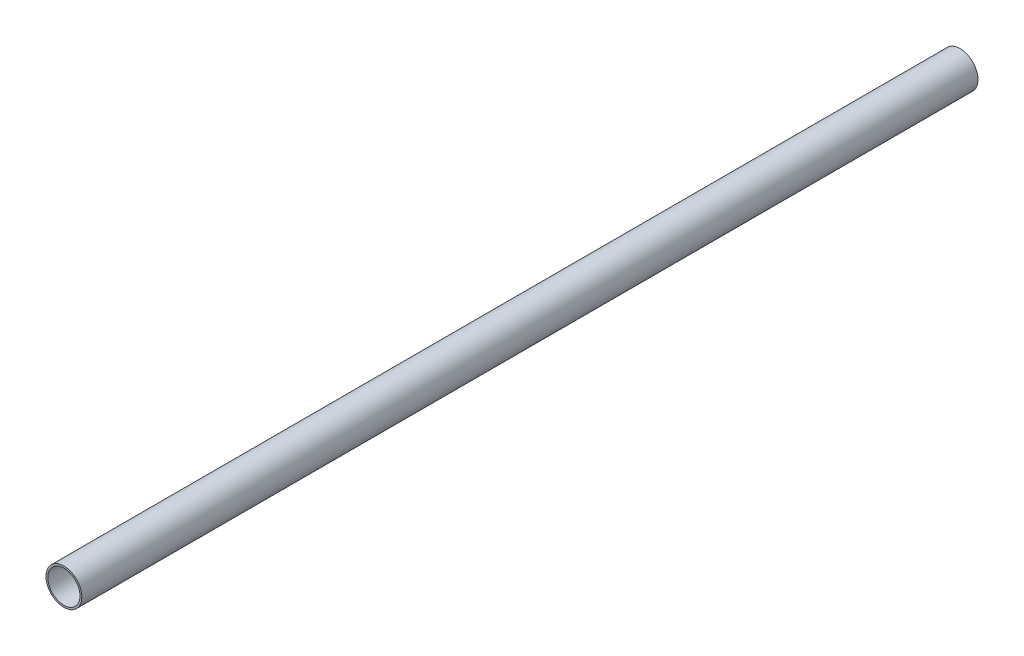
from build123d import *

# Parameters (mm, degrees)
SKETCH1_R           = 20
SKETCH1_R_2         = 18
BOSS_EXTRUDE1_DEPTH = 1000


with BuildPart() as part:
    # Sketch1 → Boss-Extrude1 (new body)
    with BuildSketch(Plane.XY):
        Circle(SKETCH1_R)
        Circle(SKETCH1_R_2, mode=Mode.SUBTRACT)
    extrude(amount=BOSS_EXTRUDE1_DEPTH)


solid = part.part
